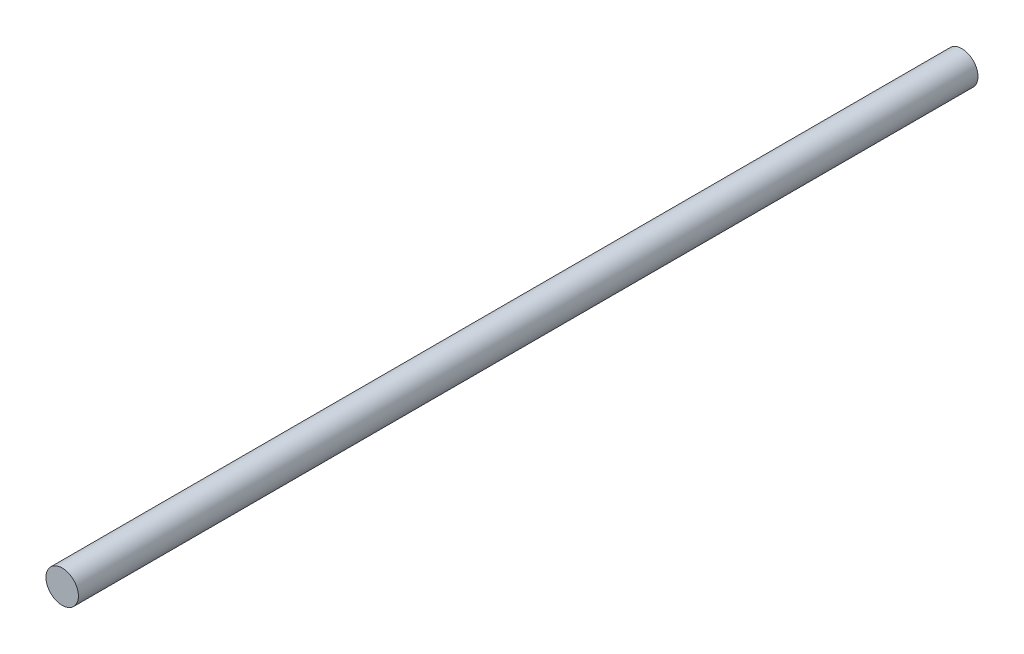
from build123d import *

# Parameters (mm, degrees)
SKETCH1_R           = 5
BOSS_EXTRUDE1_DEPTH = 277.5


with BuildPart() as part:
    # Sketch1 → Boss-Extrude1 (new body)
    with BuildSketch(Plane.XY):
        Circle(SKETCH1_R)
    extrude(amount=BOSS_EXTRUDE1_DEPTH)


solid = part.part
